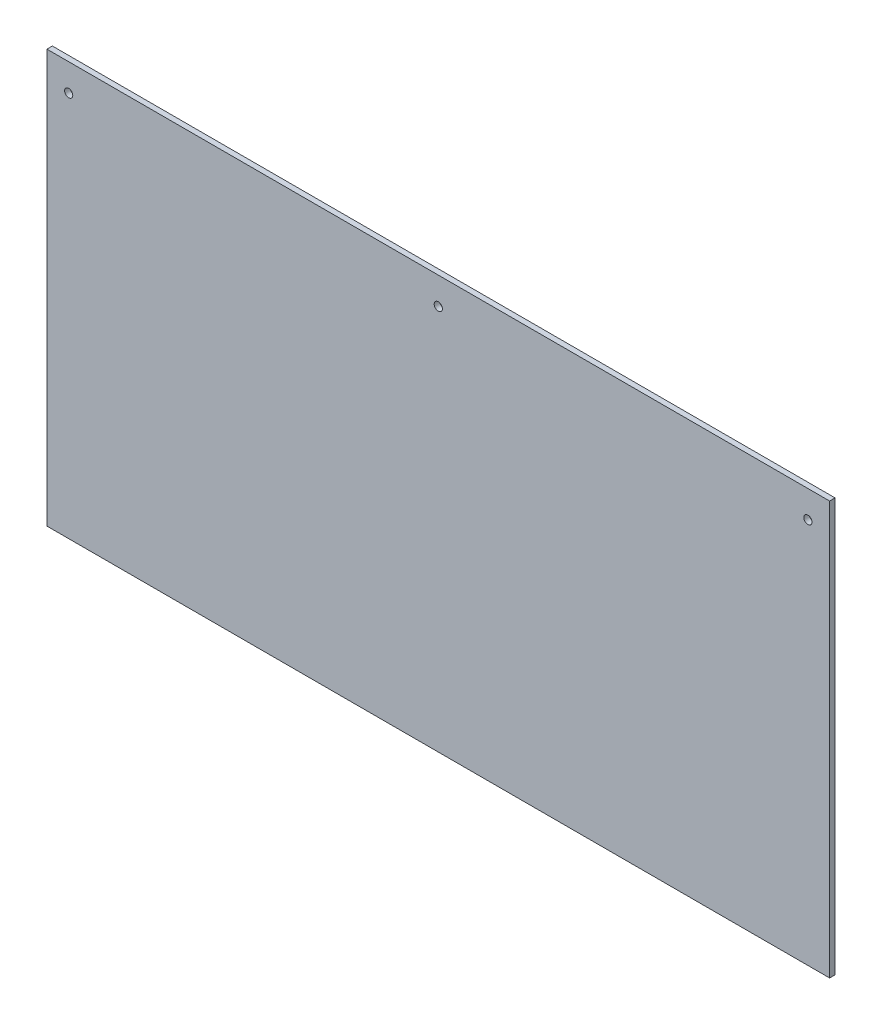
from build123d import *

# Parameters (mm, degrees)
SKETCH1_W           = 914.4
SKETCH1_H           = 482.6
BOSS_EXTRUDE1_DEPTH = 6.35
SKETCH2_R           = 4.7625
CUT_EXTRUDE1_DEPTH  = 7.35
LPATTERN1_COUNT     = 3
LPATTERN1_PITCH     = 431.8


with BuildPart() as part:
    # Sketch1 → Boss-Extrude1 (new body)
    with BuildSketch(Plane.XY):
        with Locations((457.2, 241.3)):
            Rectangle(SKETCH1_W, SKETCH1_H)
    extrude(amount=BOSS_EXTRUDE1_DEPTH)

    # Sketch2 → Cut-Extrude1 (cut, through all)
    with BuildSketch(Plane.XY.offset(6.35)):
        with Locations((25.4, 450.85)):
            Circle(SKETCH2_R)
    cut_extrude1 = extrude(amount=-CUT_EXTRUDE1_DEPTH, mode=Mode.SUBTRACT)

    # LPattern1: Cut-Extrude1 ×3
    with Locations(*[(i * LPATTERN1_PITCH, 0, 0) for i in range(1, LPATTERN1_COUNT)]):
        add(cut_extrude1, mode=Mode.SUBTRACT)


solid = part.part
